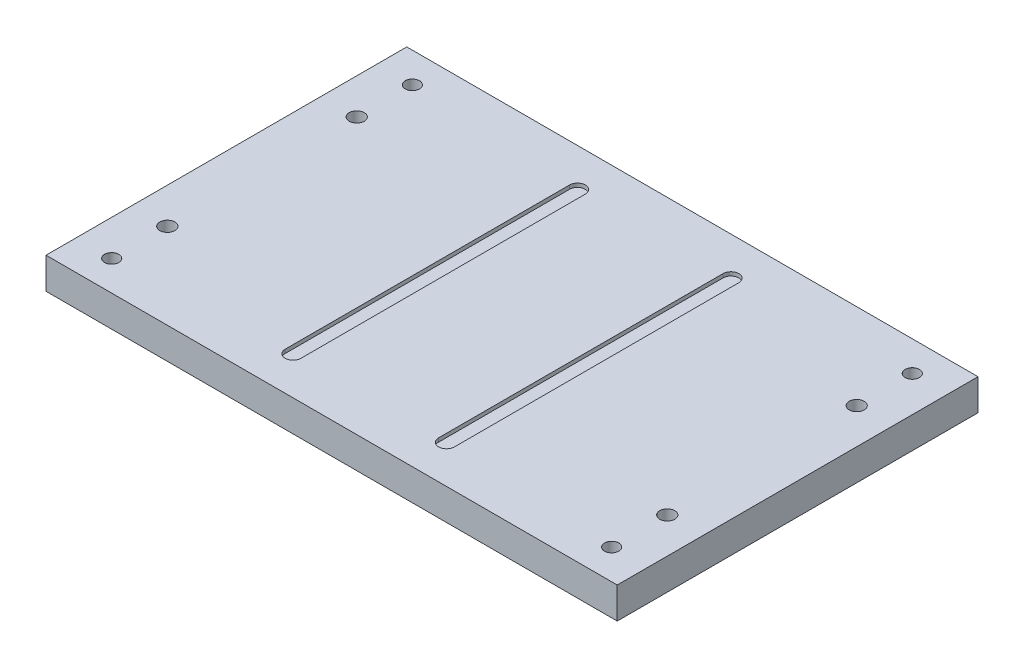
from build123d import *

# Parameters (mm, degrees)
SKETCH1_W                       = 482.6
SKETCH1_H                       = 304.8
BOSS_EXTRUDE1_DEPTH             = 26.416
CUT_EXTRUDE3_DEPTH              = 3.175
SKETCH3_R                       = 6.35
SKETCH3_R_2                     = 2.54
CUT_EXTRUDE2_DEPTH              = 27.416
M10_CLEARANCE_HOLE2_D           = 12
M10_CLEARANCE_HOLE2_CSINK_D     = 12.05
M10_CLEARANCE_HOLE2_CSINK_ANGLE = 90
M10_CLEARANCE_HOLE3_D           = 12
M10_CLEARANCE_HOLE3_CSINK_D     = 12.05
M10_CLEARANCE_HOLE3_CSINK_ANGLE = 90


with BuildPart() as part:
    # Sketch1 → Boss-Extrude1 (new body)
    with BuildSketch(Plane(origin=(0, 0, 0), x_dir=(1, 0, 0), z_dir=(0, 1, 0))):
        Rectangle(SKETCH1_W, SKETCH1_H)
    extrude(amount=BOSS_EXTRUDE1_DEPTH)

    # Sketch2 → Cut-Extrude3 (cut)
    with BuildSketch(Plane(origin=(0, 26.416, 0), x_dir=(1, 0, 0), z_dir=(0, 1, 0))):
        with BuildLine():
            Line((-71.501, 120.142), (-71.501, -120.142))
            ThreePointArc((-71.501, -120.142), (-64.8335, -113.4745), (-58.166, -120.142))
            Line((-58.166, -120.142), (-58.166, 120.142))
            ThreePointArc((-58.166, 120.142), (-64.8335, 113.4745), (-71.501, 120.142))
        make_face()
        with BuildLine():
            ThreePointArc((-58.166, 120.142), (-64.8335, 126.8095), (-71.501, 120.142))
            Line((-71.501, 120.142), (-58.166, 120.142))
        make_face()
        with BuildLine():
            Line((-58.166, 120.142), (-71.501, 120.142))
            ThreePointArc((-71.501, 120.142), (-64.8335, 113.4745), (-58.166, 120.142))
        make_face()
        with BuildLine():
            ThreePointArc((-58.166, -120.142), (-64.8335, -113.4745), (-71.501, -120.142))
            Line((-71.501, -120.142), (-58.166, -120.142))
        make_face()
        with BuildLine():
            Line((-58.166, -120.142), (-71.501, -120.142))
            ThreePointArc((-71.501, -120.142), (-64.8335, -126.8095), (-58.166, -120.142))
        make_face()
        with BuildLine():
            ThreePointArc((58.166, 120.142), (64.8335, 113.4745), (71.501, 120.142))
            Line((71.501, 120.142), (58.166, 120.142))
        make_face()
        with BuildLine():
            Line((58.166, 120.142), (71.501, 120.142))
            ThreePointArc((71.501, 120.142), (64.8335, 126.8095), (58.166, 120.142))
        make_face()
        with BuildLine():
            Line((71.501, -120.142), (71.501, 120.142))
            ThreePointArc((71.501, 120.142), (64.8335, 113.4745), (58.166, 120.142))
            Line((58.166, 120.142), (58.166, -120.142))
            ThreePointArc((58.166, -120.142), (64.8335, -113.4745), (71.501, -120.142))
        make_face()
        with BuildLine():
            ThreePointArc((58.166, -120.142), (64.8335, -126.8095), (71.501, -120.142))
            Line((71.501, -120.142), (58.166, -120.142))
        make_face()
        with BuildLine():
            Line((58.166, -120.142), (71.501, -120.142))
            ThreePointArc((71.501, -120.142), (64.8335, -113.4745), (58.166, -120.142))
        make_face()
    extrude(amount=-CUT_EXTRUDE3_DEPTH, mode=Mode.SUBTRACT)

    # Sketch3 → Cut-Extrude2 (cut, through all)
    with BuildSketch(Plane(origin=(0, 26.416, 0), x_dir=(1, 0, 0), z_dir=(0, 1, 0))):
        with Locations((-211.201, -80.01)):
            Circle(SKETCH3_R)
        with Locations((-211.201, 80.01)):
            Circle(SKETCH3_R)
        with Locations((211.201, -80.01)):
            Circle(SKETCH3_R)
        with Locations((211.201, 80.01)):
            Circle(SKETCH3_R)
        with Locations((-211.201, -127)):
            Circle(SKETCH3_R_2)
        with Locations((-211.201, 127)):
            Circle(SKETCH3_R_2)
        with Locations((211.201, -127)):
            Circle(SKETCH3_R_2)
        with Locations((211.201, 127)):
            Circle(SKETCH3_R_2)
    extrude(amount=-CUT_EXTRUDE2_DEPTH, mode=Mode.SUBTRACT)

    # M10 Clearance Hole2 (through all)
    with Locations(Plane(origin=(0, 26.416, 0), x_dir=(1, 0, 0), z_dir=(0, 1, 0))):
        with Locations((-211.201, -127)):
            CounterSinkHole(M10_CLEARANCE_HOLE2_D / 2, M10_CLEARANCE_HOLE2_CSINK_D / 2, counter_sink_angle=M10_CLEARANCE_HOLE2_CSINK_ANGLE)

    # M10 Clearance Hole3 (through all)
    with Locations(Plane(origin=(0, 26.416, 0), x_dir=(1, 0, 0), z_dir=(0, 1, 0))):
        with Locations((-211.201, 127), (211.201, 127), (211.201, -127)):
            CounterSinkHole(M10_CLEARANCE_HOLE3_D / 2, M10_CLEARANCE_HOLE3_CSINK_D / 2, counter_sink_angle=M10_CLEARANCE_HOLE3_CSINK_ANGLE)


solid = part.part
